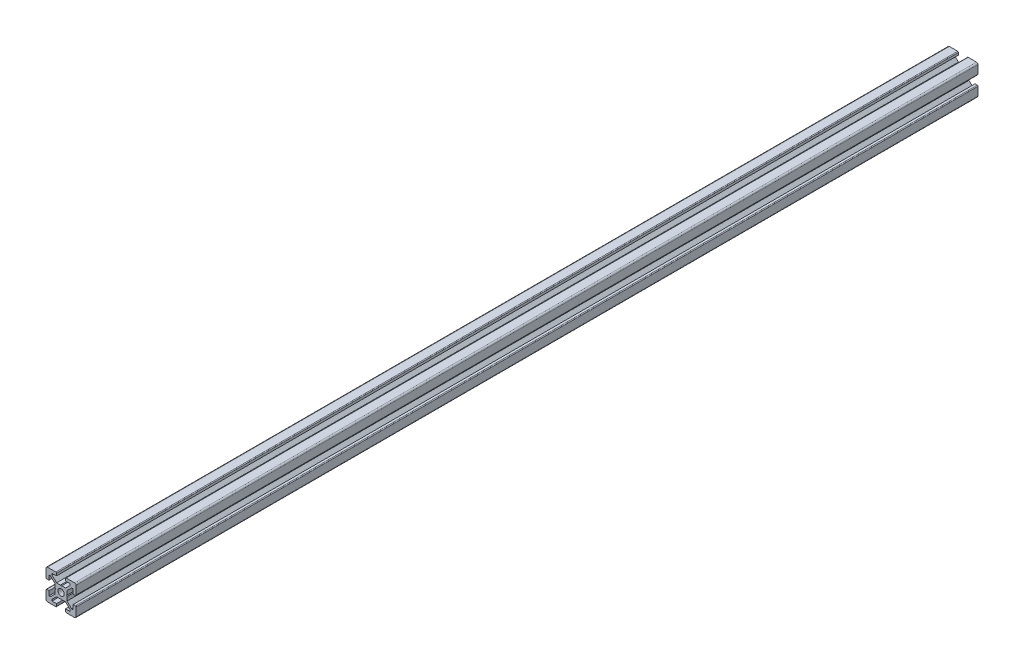
from build123d import *

# Parameters (mm, degrees)
SCHIZZO1_R                   = 2.1
ESTRUSIONE_ESTRUSIONE1_DEPTH = 600


with BuildPart() as part:
    # Schizzo1 → Estrusione-Estrusione1 (new body)
    with BuildSketch(Plane.XY):
        with BuildLine():
            Line((-3.6, 0), (-4, 0.4))
            Line((-4, 0.4), (-4, 3))
            Line((-4, 3), (-7, 6))
            Line((-7, 6), (-8, 6))
            Line((-8, 6), (-8, 3))
            Line((-8, 3), (-9.5, 3))
            ThreePointArc((-9.5, 3), (-9.853553391, 3.146446609), (-10, 3.5))
            Line((-10, 3.5), (-10, 9))
            ThreePointArc((-10, 9), (-9.707106781, 9.707106781), (-9, 10))
            Line((-9, 10), (-3.5, 10))
            ThreePointArc((-3.5, 10), (-3.146446609, 9.853553391), (-3, 9.5))
            Line((-3, 9.5), (-3, 8))
            Line((-3, 8), (-6, 8))
            Line((-6, 8), (-6, 7))
            Line((-6, 7), (-3, 4))
            Line((-3, 4), (-0.4, 4))
            Line((-0.4, 4), (0, 3.6))
            Line((0, 3.6), (0.4, 4))
            Line((0.4, 4), (3, 4))
            Line((3, 4), (6, 7))
            Line((6, 7), (6, 8))
            Line((6, 8), (3, 8))
            Line((3, 8), (3, 9.5))
            ThreePointArc((3, 9.5), (3.146446609, 9.853553391), (3.5, 10))
            Line((3.5, 10), (9, 10))
            ThreePointArc((9, 10), (9.707106781, 9.707106781), (10, 9))
            Line((10, 9), (10, 3.5))
            ThreePointArc((10, 3.5), (9.853553391, 3.146446609), (9.5, 3))
            Line((9.5, 3), (8, 3))
            Line((8, 3), (8, 6))
            Line((8, 6), (7, 6))
            Line((7, 6), (4, 3))
            Line((4, 3), (4, 0.4))
            Line((4, 0.4), (3.6, 0))
            Line((3.6, 0), (4, -0.4))
            Line((4, -0.4), (4, -3))
            Line((4, -3), (7, -6))
            Line((7, -6), (8, -6))
            Line((8, -6), (8, -3))
            Line((8, -3), (9.5, -3))
            ThreePointArc((9.5, -3), (9.853553391, -3.146446609), (10, -3.5))
            Line((10, -3.5), (10, -9))
            ThreePointArc((10, -9), (9.707106781, -9.707106781), (9, -10))
            Line((9, -10), (3.5, -10))
            ThreePointArc((3.5, -10), (3.146446609, -9.853553391), (3, -9.5))
            Line((3, -9.5), (3, -8))
            Line((3, -8), (6, -8))
            Line((6, -8), (6, -7))
            Line((6, -7), (3, -4))
            Line((3, -4), (0.4, -4))
            Line((0.4, -4), (0, -3.6))
            Line((0, -3.6), (-0.4, -4))
            Line((-0.4, -4), (-3, -4))
            Line((-3, -4), (-6, -7))
            Line((-6, -7), (-6, -8))
            Line((-6, -8), (-3, -8))
            Line((-3, -8), (-3, -9.5))
            ThreePointArc((-3, -9.5), (-3.146446609, -9.853553391), (-3.5, -10))
            Line((-3.5, -10), (-9, -10))
            ThreePointArc((-9, -10), (-9.707106781, -9.707106781), (-10, -9))
            Line((-10, -9), (-10, -3.5))
            ThreePointArc((-10, -3.5), (-9.853553391, -3.146446609), (-9.5, -3))
            Line((-9.5, -3), (-8, -3))
            Line((-8, -3), (-8, -6))
            Line((-8, -6), (-7, -6))
            Line((-7, -6), (-4, -3))
            Line((-4, -3), (-4, -0.4))
            Line((-4, -0.4), (-3.6, 0))
        make_face()
        Circle(SCHIZZO1_R, mode=Mode.SUBTRACT)
    extrude(amount=ESTRUSIONE_ESTRUSIONE1_DEPTH)


solid = part.part
